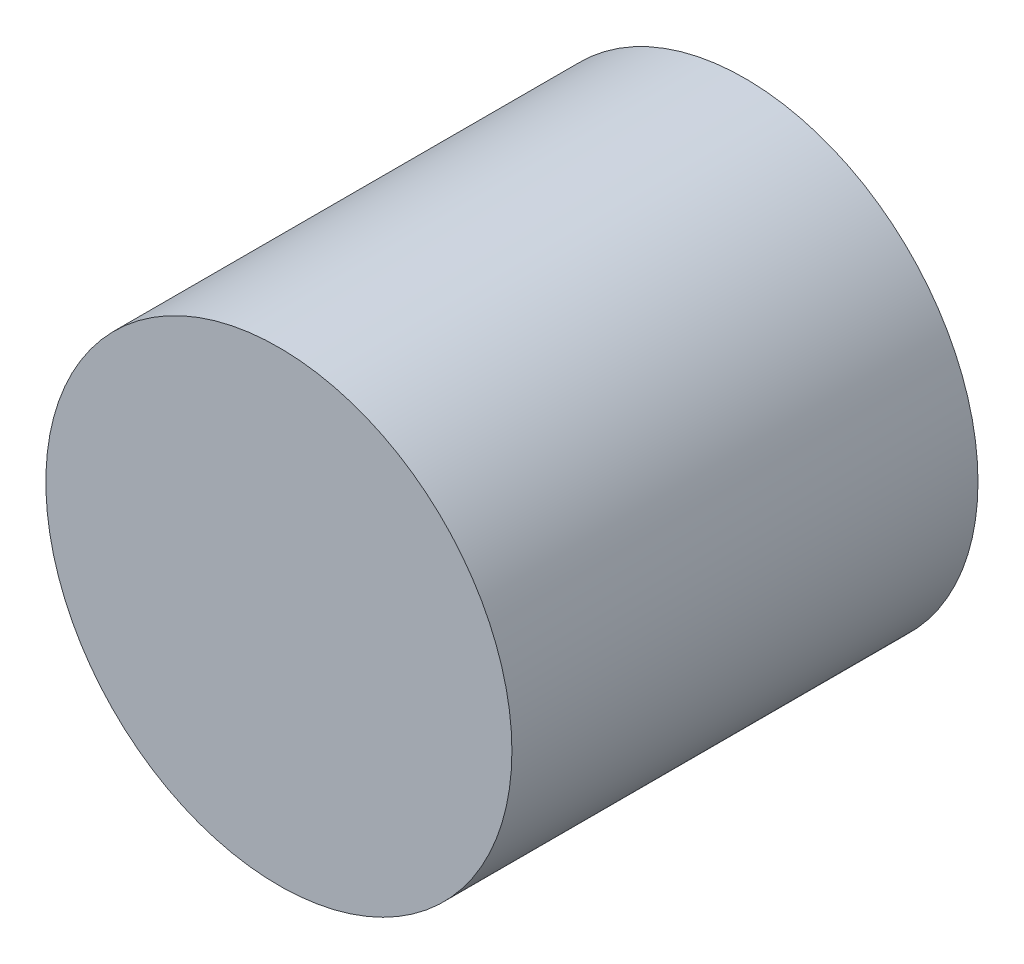
from build123d import *

# Parameters (mm, degrees)
SKETCH1_R           = 12.7
BOSS_EXTRUDE1_DEPTH = 25.4


with BuildPart() as part:
    # Sketch1 → Boss-Extrude1 (new body)
    with BuildSketch(Plane.XY):
        Circle(SKETCH1_R)
    extrude(amount=BOSS_EXTRUDE1_DEPTH)


solid = part.part
